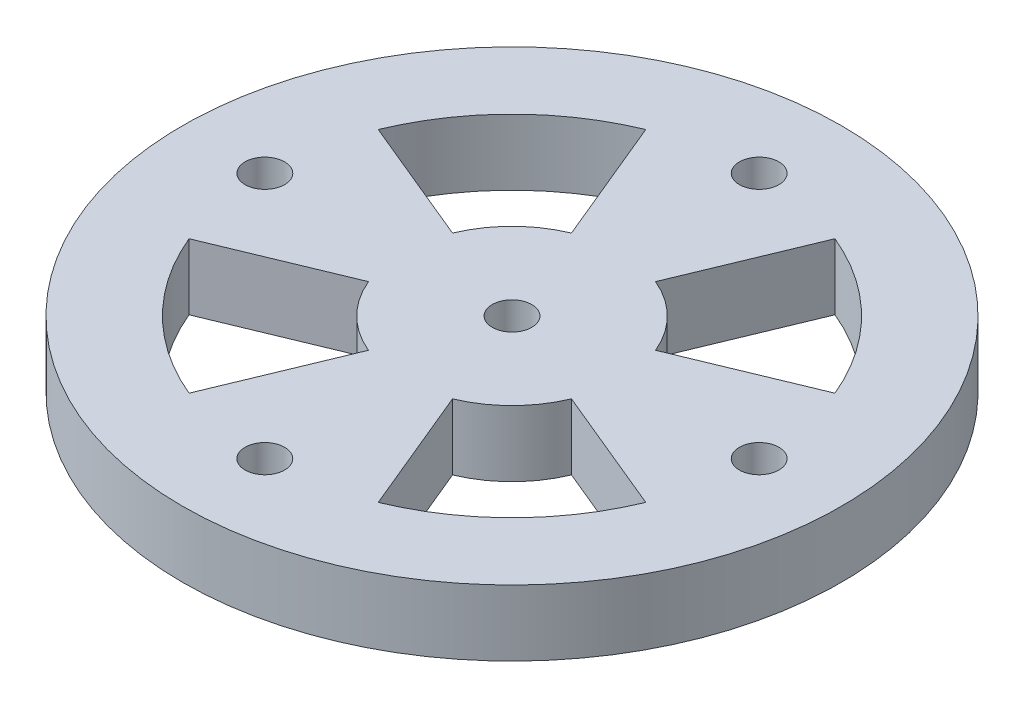
from build123d import *

# Parameters (mm, degrees)
SKETCH1_R           = 25
SKETCH1_R_2         = 1.5
BOSS_EXTRUDE1_DEPTH = 5


with BuildPart() as part:
    # Sketch1 → Boss-Extrude1 (new body)
    with BuildSketch(Plane(origin=(0, 0, 0), x_dir=(1, 0, 0), z_dir=(0, 1, 0))):
        Circle(SKETCH1_R)
        Circle(SKETCH1_R_2, mode=Mode.SUBTRACT)
        with Locations((18.75, 0)):
            Circle(SKETCH1_R_2, mode=Mode.SUBTRACT)
        with Locations((0, -18.75)):
            Circle(SKETCH1_R_2, mode=Mode.SUBTRACT)
        with Locations((-18.75, 0)):
            Circle(SKETCH1_R_2, mode=Mode.SUBTRACT)
        with Locations((0, 18.75)):
            Circle(SKETCH1_R_2, mode=Mode.SUBTRACT)
        with BuildLine():
            Line((7.698996104, 3.189028603), (17.322741235, 7.175314357))
            ThreePointArc((17.322741235, 7.175314357), (13.258252147, 13.258252147), (7.175314357, 17.322741235))
            Line((7.175314357, 17.322741235), (3.189028603, 7.698996104))
            ThreePointArc((3.189028603, 7.698996104), (5.89255651, 5.89255651), (7.698996104, 3.189028603))
        make_face(mode=Mode.SUBTRACT)
        with BuildLine():
            Line((3.189028603, -7.698996104), (7.175314357, -17.322741235))
            ThreePointArc((7.175314357, -17.322741235), (13.258252147, -13.258252147), (17.322741235, -7.175314357))
            Line((17.322741235, -7.175314357), (7.698996104, -3.189028603))
            ThreePointArc((7.698996104, -3.189028603), (5.89255651, -5.89255651), (3.189028603, -7.698996104))
        make_face(mode=Mode.SUBTRACT)
        with BuildLine():
            Line((-7.698996104, -3.189028603), (-17.322741235, -7.175314357))
            ThreePointArc((-17.322741235, -7.175314357), (-13.258252147, -13.258252147), (-7.175314357, -17.322741235))
            Line((-7.175314357, -17.322741235), (-3.189028603, -7.698996104))
            ThreePointArc((-3.189028603, -7.698996104), (-5.89255651, -5.89255651), (-7.698996104, -3.189028603))
        make_face(mode=Mode.SUBTRACT)
        with BuildLine():
            Line((-7.698996104, 3.189028603), (-17.322741235, 7.175314357))
            ThreePointArc((-17.322741235, 7.175314357), (-13.258252147, 13.258252147), (-7.175314357, 17.322741235))
            Line((-7.175314357, 17.322741235), (-3.189028603, 7.698996104))
            ThreePointArc((-3.189028603, 7.698996104), (-5.89255651, 5.89255651), (-7.698996104, 3.189028603))
        make_face(mode=Mode.SUBTRACT)
    extrude(amount=BOSS_EXTRUDE1_DEPTH)


solid = part.part
